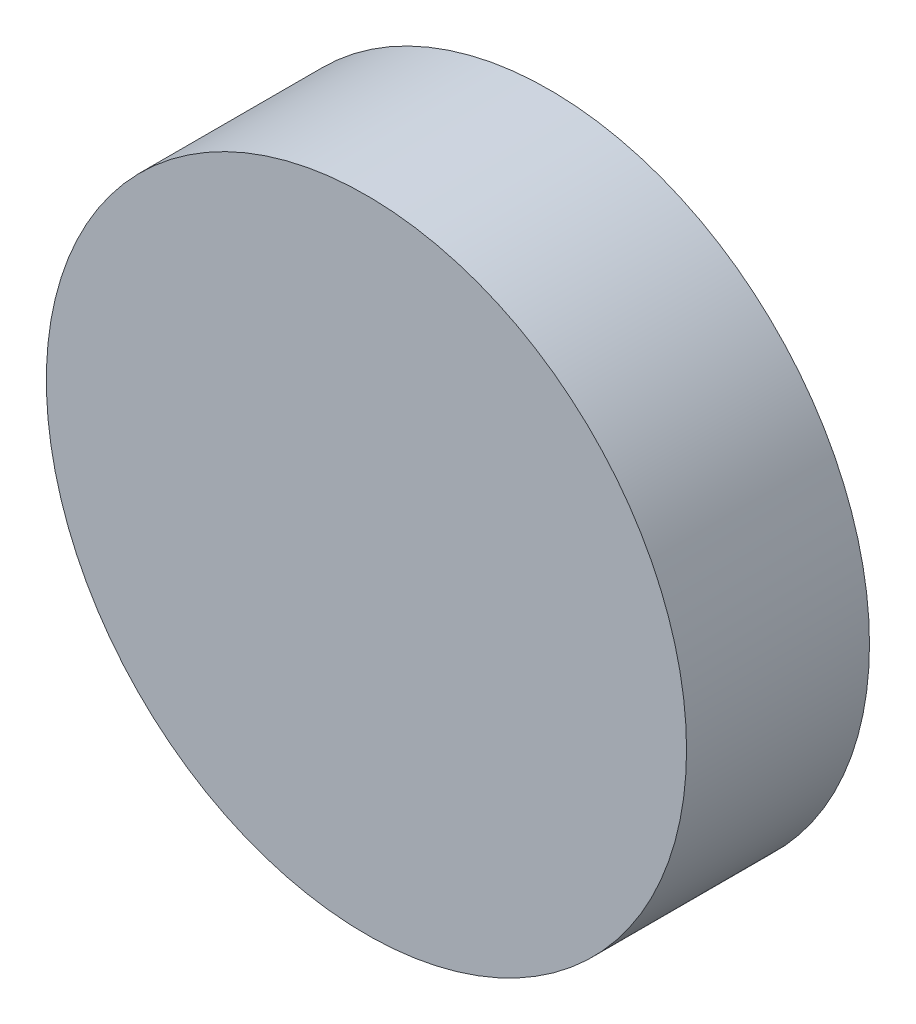
from build123d import *

# Parameters (mm, degrees)
SKETCH1_R           = 1.75
BOSS_EXTRUDE1_DEPTH = 1


with BuildPart() as part:
    # Sketch1 → Boss-Extrude1 (new body)
    with BuildSketch(Plane.XY):
        Circle(SKETCH1_R)
    extrude(amount=BOSS_EXTRUDE1_DEPTH)


solid = part.part
